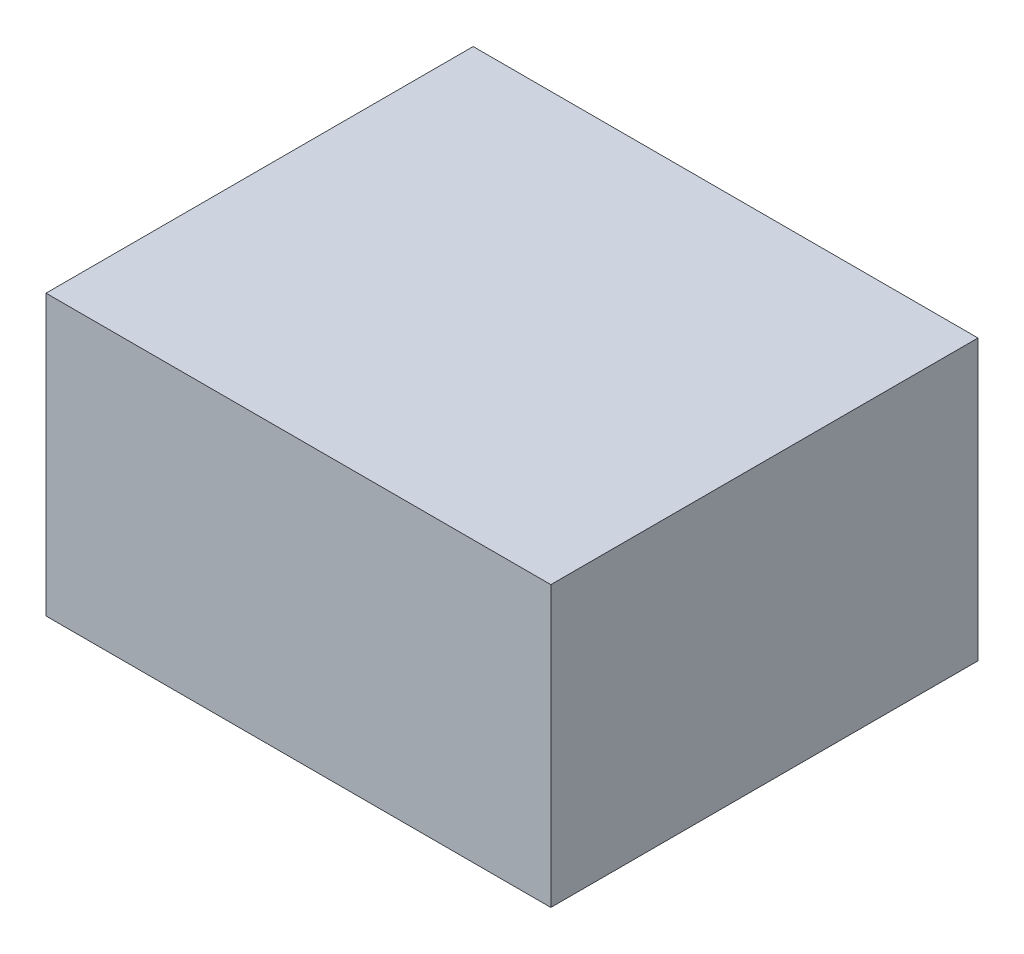
from build123d import *

# Parameters (mm, degrees)
SKETCH_1_W          = 65
SKETCH_1_H          = 55
EXTRUDE_1_DEPTH     = 35
CUT_EXTRUDE_1_DEPTH = 34
SKETCH_3_W          = 65
SKETCH_3_H          = 55
EXTRUDE_2_DEPTH     = 1


with BuildPart() as part:
    # Эскиз1 → Бобышка-Вытянуть1 (new body)
    with BuildSketch(Plane(origin=(0, 0, 0), x_dir=(1, 0, 0), z_dir=(0, 1, 0))):
        with Locations((-23.213428901, -3.437024221)):
            Rectangle(SKETCH_1_W, SKETCH_1_H)
    extrude(amount=EXTRUDE_1_DEPTH)

    # Эскиз2 → Вырез-Вытянуть1 (cut)
    with BuildSketch(Plane(origin=(0, 35, 0), x_dir=(1, 0, 0), z_dir=(0, 1, 0))):
        Polygon((-55.213428901, 23.562975779), (-55.213428901, -29.063319013), (-55.213428901, -30.437024221), (8.786571099, -30.437024221), (8.786571099, 23.562975779), align=None)
    extrude(amount=-CUT_EXTRUDE_1_DEPTH, mode=Mode.SUBTRACT)

    # Эскиз3 → Бобышка-Вытянуть2 (add)
    with BuildSketch(Plane(origin=(0, 35, 0), x_dir=(1, 0, 0), z_dir=(0, 1, 0))):
        with Locations((-23.213428901, -3.437024221)):
            Rectangle(SKETCH_3_W, SKETCH_3_H)
    extrude(amount=EXTRUDE_2_DEPTH)


solid = part.part
